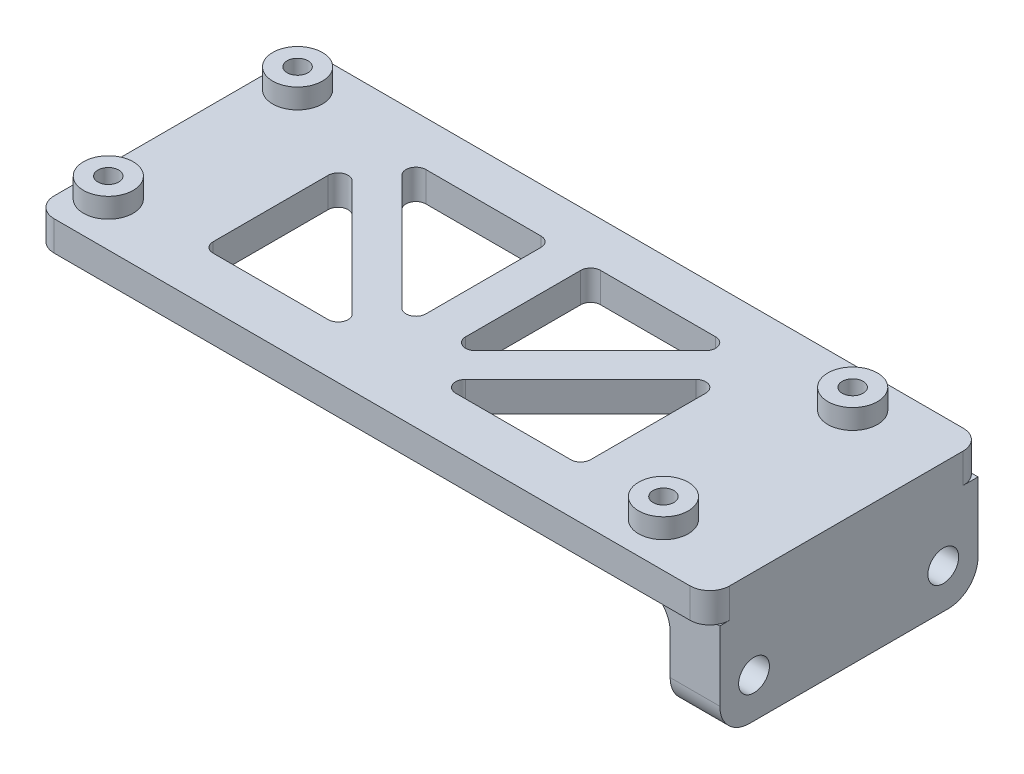
from build123d import *

# Parameters (mm, degrees)
SKETCH1_W            = 68
SKETCH1_H            = 27.5
BOSS_EXTRUDE1_DEPTH  = 3
FILLET1_R            = 2
SKETCH2_R            = 2.5
BOSS_EXTRUDE2_DEPTH  = 2
SKETCH4_R            = 1.05
CUT_EXTRUDE2_DEPTH   = 12
SKETCH5_W            = 5
SKETCH5_H            = 25.989939454
BOSS_EXTRUDE3_DEPTH  = 10
SKETCH6_R            = 1.55
CUT_EXTRUDE3_DEPTH   = 10
FILLET2_R            = 3
FILLET3_R            = 3
CUT_EXTRUDE4_DEPTH   = 10
FILLET4_R            = 1
FILLET4_OF_MIRROR1_R = 1


with BuildPart() as part:
    # Sketch1 → Boss-Extrude1 (new body)
    with BuildSketch(Plane(origin=(0, 0, 0), x_dir=(1, 0, 0), z_dir=(0, 1, 0))):
        with Locations((3, -0.25)):
            Rectangle(SKETCH1_W, SKETCH1_H)
    extrude(amount=BOSS_EXTRUDE1_DEPTH)

    # Fillet1
    fillet1_edges = [part.edges().sort_by_distance(p)[0] for p in [
        (-31, 1.5, -13.5),
        (37, 1.5, -13.5),
        (37, 1.5, 14),
        (-31, 1.5, 14),
    ]]
    fillet(fillet1_edges, radius=FILLET1_R)

    # Sketch2 → Boss-Extrude2 (add)
    with BuildSketch(Plane(origin=(0, 3, 0), x_dir=(1, 0, 0), z_dir=(0, 1, 0))):
        with Locations((-28, 9.5)):
            Circle(SKETCH2_R)
        with Locations((27.88, 9.5)):
            Circle(SKETCH2_R)
        with Locations((27.88, -9.55)):
            Circle(SKETCH2_R)
        with Locations((-28, -9.55)):
            Circle(SKETCH2_R)
    extrude(amount=BOSS_EXTRUDE2_DEPTH)

    # Sketch4 → Cut-Extrude2 (cut)
    with BuildSketch(Plane(origin=(0, 5, 0), x_dir=(1, 0, 0), z_dir=(0, 1, 0))):
        with Locations((-28, 9.5)):
            Circle(SKETCH4_R)
        with Locations((-28, -9.55)):
            Circle(SKETCH4_R)
        with Locations((27.88, -9.55)):
            Circle(SKETCH4_R)
        with Locations((27.88, 9.5)):
            Circle(SKETCH4_R)
    extrude(amount=-CUT_EXTRUDE2_DEPTH, mode=Mode.SUBTRACT)

    # Sketch5 → Boss-Extrude3 (add)
    with BuildSketch(Plane(origin=(0, 0, 0), x_dir=(-1, 0, 0), z_dir=(0, -1, 0))):
        with Locations((-34.5, 0)):
            Rectangle(SKETCH5_W, SKETCH5_H)
    extrude(amount=BOSS_EXTRUDE3_DEPTH)

    # Sketch6 → Cut-Extrude3 (cut)
    with BuildSketch(Plane.ZY.offset(-32)):
        with Locations((-9.5, -6)):
            Circle(SKETCH6_R)
        with Locations((9.55, -6)):
            Circle(SKETCH6_R)
    extrude(amount=-CUT_EXTRUDE3_DEPTH, mode=Mode.SUBTRACT)

    # Fillet2
    fillet2_edges = [part.edges().sort_by_distance(p)[0] for p in [
        (34.5, -10, 12.994969727),
        (34.5, -10, -12.994969727),
    ]]
    fillet(fillet2_edges, radius=FILLET2_R)

    # Fillet3
    fillet3_edges = [part.edges().sort_by_distance(p)[0] for p in [
        (32, 0, 0),
    ]]
    fillet(fillet3_edges, radius=FILLET3_R)

    # Sketch7 → Cut-Extrude4 (cut)
    with BuildSketch(Plane(origin=(0, 0, 0), x_dir=(-1, 0, 0), z_dir=(0, -1, 0))):
        Polygon((19, -9), (19, 6), (4, -9), align=None)
        Polygon((17, 9), (2, -6), (2, 9), align=None)
    cut_extrude4 = extrude(amount=-CUT_EXTRUDE4_DEPTH, mode=Mode.SUBTRACT)

    # Fillet4
    fillet4_edges = [part.edges().sort_by_distance(p)[0] for p in [
        (-2, 1.5, -9),
        (-17, 1.5, -9),
        (-2, 1.5, 6),
        (-19, 1.5, 9),
        (-4, 1.5, 9),
        (-19, 1.5, -6),
    ]]
    fillet(fillet4_edges, radius=FILLET4_R)

    # Mirror1: Cut-Extrude4 across plane
    add(cut_extrude4.mirror(Plane(origin=(0, 0, 0), x_dir=(0, 0, 1), z_dir=(1, 0, 0))), mode=Mode.SUBTRACT)

    # Fillet4 of Mirror1
    fillet4_of_mirror1_edges = [part.edges().sort_by_distance(p)[0] for p in [
        (2, 1.5, -9),
        (17, 1.5, -9),
        (2, 1.5, 6),
        (19, 1.5, 9),
        (4, 1.5, 9),
        (19, 1.5, -6),
    ]]
    fillet(fillet4_of_mirror1_edges, radius=FILLET4_OF_MIRROR1_R)


solid = part.part
